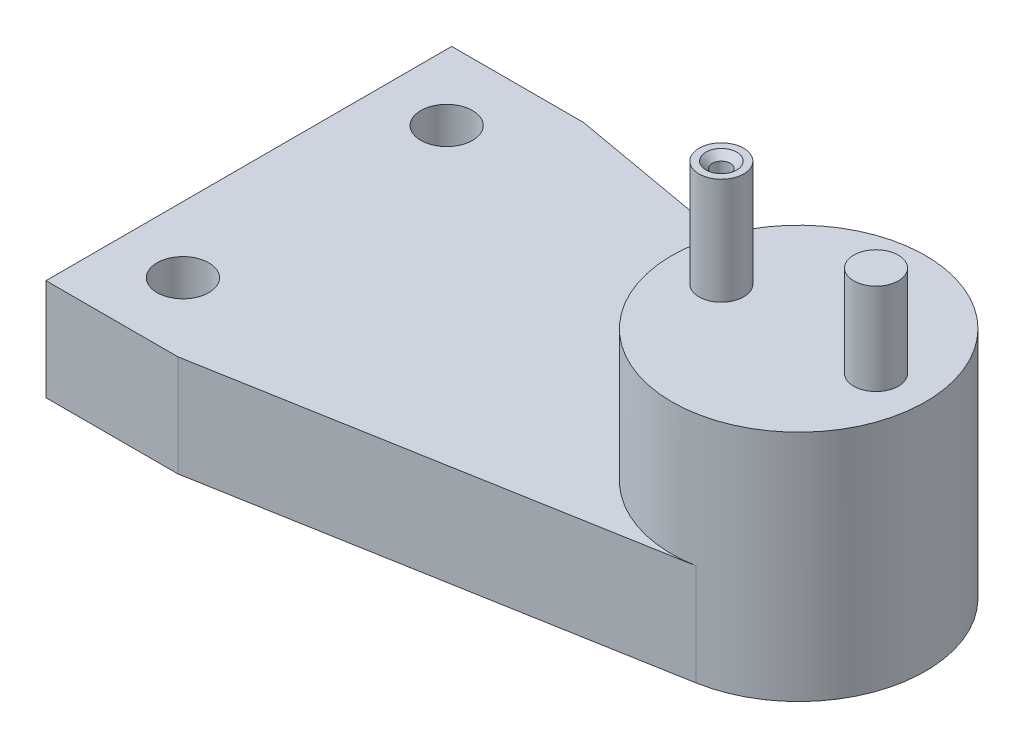
from build123d import *

# Parameters (mm, degrees)
BOSS_EXTRUDE1_DEPTH             = 10
SKETCH2_R                       = 12.5
BOSS_EXTRUDE2_DEPTH             = 13
F_10_CLEARANCE_HOLE1_D          = 5.1054
F_10_CLEARANCE_HOLE1_DEPTH      = 135.89
F_10_CLEARANCE_HOLE1_TIP        = 1.533816902
SKETCH6_R                       = 2.2
BOSS_EXTRUDE3_DEPTH             = 9
SKETCH7_R                       = 2.2
BOSS_EXTRUDE4_DEPTH             = 1.5
F_2_56_TAPPED_HOLE1_D           = 1.778
F_2_56_TAPPED_HOLE1_DEPTH       = 6.64
F_2_56_TAPPED_HOLE1_CSINK_D     = 3.048
F_2_56_TAPPED_HOLE1_CSINK_ANGLE = 90
F_2_56_TAPPED_HOLE1_TIP         = 0.53416509


with BuildPart() as part:
    # Sketch1 → Boss-Extrude1 (new body)
    with BuildSketch(Plane(origin=(0, 0, 0), x_dir=(1, 0, 0), z_dir=(0, 1, 0))):
        with BuildLine():
            Line((0, 0), (0, 20))
            Line((0, 20), (13, 20))
            Line((13, 20), (56.387051948, 12.308072526))
            ThreePointArc((56.387051948, 12.308072526), (63.784291449, 8.030390733), (66.705, 0))
            Line((66.705, 0), (0, 0))
        make_face()
    extrude(amount=BOSS_EXTRUDE1_DEPTH)

    # Mirror1: part across plane


with BuildPart() as part_1:
    add(part.part)
    add(part.part.mirror(Plane(origin=(66.705, 10, 0), x_dir=(1, 0, 0), z_dir=(0, 0, -1))))

    # Sketch2 → Boss-Extrude2 (add)
    with BuildSketch(Plane(origin=(0, 10, 0), x_dir=(1, 0, 0), z_dir=(0, 1, 0))):
        with Locations(Location((54.205, 0, 0), (0, 0, 79.946704324))):  # turned: the seam where the file's is
            Circle(SKETCH2_R)
    extrude(amount=BOSS_EXTRUDE2_DEPTH)

    # #10 Clearance Hole1
    with Locations(Plane(origin=(0, 10, 0), x_dir=(1, 0, 0), z_dir=(0, 1, 0))):
        with Locations((6.5, 13), (6.5, -13)):
            Hole(F_10_CLEARANCE_HOLE1_D / 2, depth=F_10_CLEARANCE_HOLE1_DEPTH)
            with Locations((0, 0, -(F_10_CLEARANCE_HOLE1_DEPTH + F_10_CLEARANCE_HOLE1_TIP / 2))):  # 118° drill point
                Cone(0, F_10_CLEARANCE_HOLE1_D / 2, F_10_CLEARANCE_HOLE1_TIP, mode=Mode.SUBTRACT)

    # Sketch6 → Boss-Extrude3 (add)
    with BuildSketch(Plane(origin=(0, 23, 0), x_dir=(1, 0, 0), z_dir=(0, 1, 0))):
        with Locations(Location((61.83, 0, 0), (0, 0, 270))):  # turned: the seam where the file's is
            Circle(SKETCH6_R)
        with Locations(Location((46.58, 0, 0), (0, 0, 270))):  # turned: the seam where the file's is
            Circle(SKETCH6_R)
    extrude(amount=BOSS_EXTRUDE3_DEPTH)

    # Sketch7 → Boss-Extrude4 (add)
    with BuildSketch(Plane(origin=(0, 32, 0), x_dir=(1, 0, 0), z_dir=(0, 1, 0))):
        with Locations(Location((46.58, 0, 0), (0, 0, 270))):  # turned: the seam where the file's is
            Circle(SKETCH7_R)
    extrude(amount=BOSS_EXTRUDE4_DEPTH)

    # #2-56 Tapped Hole1
    with Locations(Plane(origin=(0, 33.5, 0), x_dir=(1, 0, 0), z_dir=(0, 1, 0))):
        with Locations((46.58, 0)):
            CounterSinkHole(F_2_56_TAPPED_HOLE1_D / 2, F_2_56_TAPPED_HOLE1_CSINK_D / 2, depth=F_2_56_TAPPED_HOLE1_DEPTH, counter_sink_angle=F_2_56_TAPPED_HOLE1_CSINK_ANGLE)
            with Locations((0, 0, -(F_2_56_TAPPED_HOLE1_DEPTH + F_2_56_TAPPED_HOLE1_TIP / 2))):  # 118° drill point
                Cone(0, F_2_56_TAPPED_HOLE1_D / 2, F_2_56_TAPPED_HOLE1_TIP, mode=Mode.SUBTRACT)


solid = part_1.part
